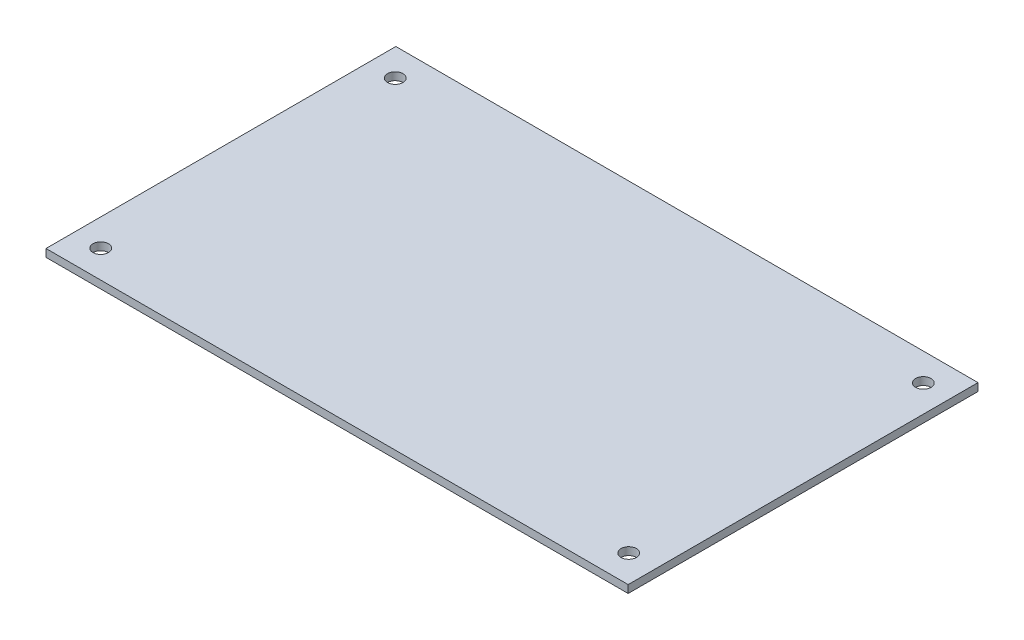
from build123d import *

# Parameters (mm, degrees)
SKETCH1_W           = 150.6
SKETCH1_H           = 90.5
SKETCH1_R           = 2
BOSS_EXTRUDE1_DEPTH = 2


with BuildPart() as part:
    # Sketch1 → Boss-Extrude1 (new body)
    with BuildSketch(Plane(origin=(0, 0, 0), x_dir=(1, 0, 0), z_dir=(0, 1, 0))):
        Rectangle(SKETCH1_W, SKETCH1_H)
        with Locations((-68.3, 38.1)):
            Circle(SKETCH1_R, mode=Mode.SUBTRACT)
        with Locations((-68.3, -38.1)):
            Circle(SKETCH1_R, mode=Mode.SUBTRACT)
        with Locations((68.3, 38.1)):
            Circle(SKETCH1_R, mode=Mode.SUBTRACT)
        with Locations((68.3, -38.1)):
            Circle(SKETCH1_R, mode=Mode.SUBTRACT)
    extrude(amount=BOSS_EXTRUDE1_DEPTH)


solid = part.part
